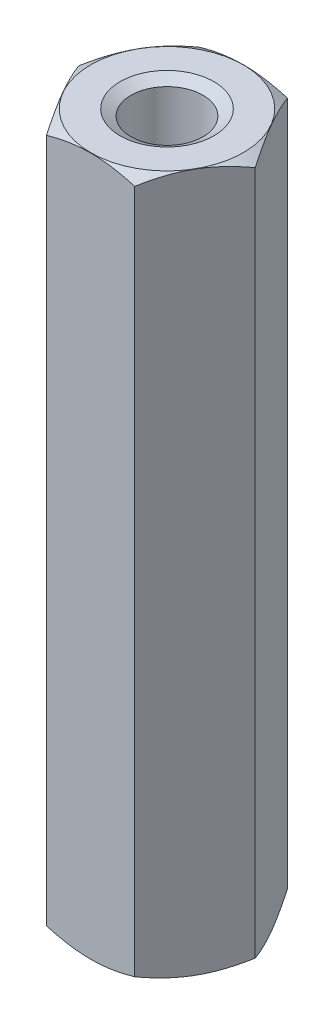
from build123d import *

# Parameters (mm, degrees)
SKETCH1_R             = 4.041451884
SKETCH1_R_2           = 1.65
BOSS_EXTRUDE1_DEPTH   = 32
CHAMFER1_SIZE         = 0.55
CHAMFER1_SIZE2        = 0.317542648
CHAMFER2_SIZE         = 0.55
CHAMFER2_SIZE2        = 0.317542648
SKETCH2_OUTSIDE_W     = 16.878
SKETCH2_OUTSIDE_H     = 16.878
CUT_EXTRUDE1_DEPTH    = 33
CHAMFER3_SIZE         = 0.5
CHAMFER3_SIZE2        = 0.288675135
CHAMFER3_PART_2_SIZE  = 0.5
CHAMFER3_PART_2_SIZE2 = 0.288675135
SKETCH3_W             = 4.041451884
SKETCH3_H             = 12
BOSS_EXTRUDE2_DEPTH   = 7


with BuildPart() as part:
    # Sketch1 → Boss-Extrude1 (new body)
    with BuildSketch(Plane(origin=(0, 0, 0), x_dir=(1, 0, 0), z_dir=(0, 1, 0))):
        Circle(SKETCH1_R)
        Circle(SKETCH1_R_2, mode=Mode.SUBTRACT)
    extrude(amount=BOSS_EXTRUDE1_DEPTH)

    # Chamfer1
    chamfer1_edges = [part.edges().sort_by_distance(p)[0] for p in [
        (-4.041451884, 32, 0),
    ]]
    chamfer1_side = [part.faces().sort_by_distance(p)[0] for p in [
        (-3.927142363, 32, 0),
    ]]
    chamfer(chamfer1_edges, length=CHAMFER1_SIZE, length2=CHAMFER1_SIZE2, reference=chamfer1_side[0])

    # Chamfer2
    chamfer2_edges = [part.edges().sort_by_distance(p)[0] for p in [
        (-4.041451884, 0, 0),
    ]]
    chamfer2_side = [part.faces().sort_by_distance(p)[0] for p in [
        (-3.927142363, 0, 0),
    ]]
    chamfer(chamfer2_edges, length=CHAMFER2_SIZE, length2=CHAMFER2_SIZE2, reference=chamfer2_side[0])

    # Sketch2 outside → Cut-Extrude1 (cut, through all)
    with BuildSketch(Plane.XZ):
        Rectangle(SKETCH2_OUTSIDE_W, SKETCH2_OUTSIDE_H)
        Polygon((4.041451884, 0), (2.020725942, -3.5), (-2.020725942, -3.5), (-4.041451884, 0), (-2.020725942, 3.5), (2.020725942, 3.5), align=None, mode=Mode.SUBTRACT)
    extrude(amount=-CUT_EXTRUDE1_DEPTH, mode=Mode.SUBTRACT)

    # Chamfer3
    chamfer3_edges = [part.edges().sort_by_distance(p)[0] for p in [
        (-1.65, 0, 0),
    ]]
    chamfer3_side = [part.faces().sort_by_distance(p)[0] for p in [
        (-1.65, 16, 0),
    ]]
    chamfer(chamfer3_edges, length=CHAMFER3_SIZE, length2=CHAMFER3_SIZE2, reference=chamfer3_side[0])

    # Chamfer3 part 2
    chamfer3_part_2_edges = [part.edges().sort_by_distance(p)[0] for p in [
        (-1.65, 32, 0),
    ]]
    chamfer3_part_2_side = [part.faces().sort_by_distance(p)[0] for p in [
        (-3.392698712, 32, 0),
    ]]
    chamfer(chamfer3_part_2_edges, length=CHAMFER3_PART_2_SIZE, length2=CHAMFER3_PART_2_SIZE2, reference=chamfer3_part_2_side[0])

    # Sketch3 → Boss-Extrude2 (add)
    with BuildSketch(Plane(origin=(-3.031088913, 0, -1.75), x_dir=(-0.5, 0, 0.866025404), z_dir=(-0.866025404, 0, -0.5))):
        with Locations((0, 16)):
            Rectangle(SKETCH3_W, SKETCH3_H)
    extrude(amount=-BOSS_EXTRUDE2_DEPTH)


solid = part.part
